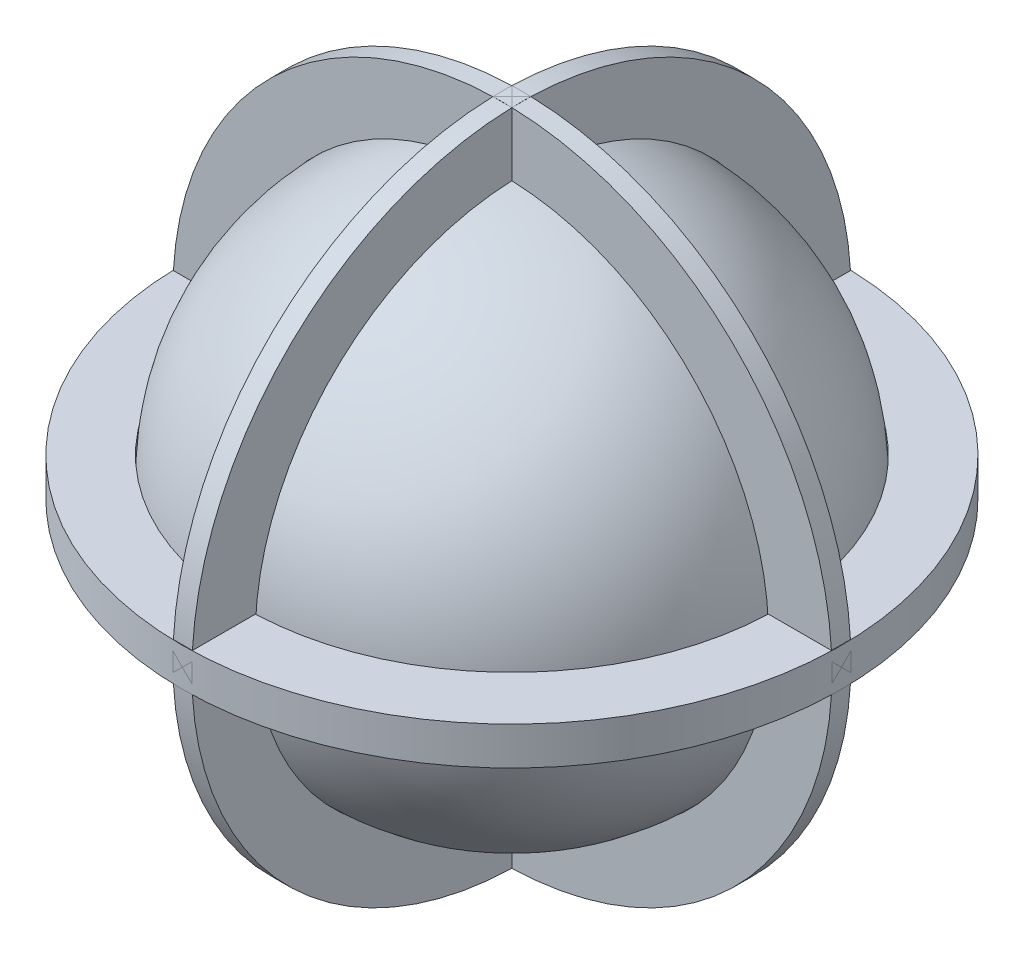
from build123d import *

# Parameters (mm, degrees)
SKETCH2_R           = 52
SKETCH2_R_2         = 42
BOSS_EXTRUDE1_DEPTH = 1.5
SKETCH4_R           = 52
SKETCH4_R_2         = 42
BOSS_EXTRUDE2_DEPTH = 1.5
SKETCH5_R           = 52
SKETCH5_R_2         = 42
BOSS_EXTRUDE3_DEPTH = 3


with BuildPart() as part:
    # Sketch1 one side → Revolve3 (revolve)
    with BuildSketch(Plane.XY):
        with BuildLine():
            Line((0, 40), (0, 42))
            ThreePointArc((0, 42), (-42, 0), (0, -42))
            Line((0, -42), (0, -40))
            ThreePointArc((0, -40), (-40, 0), (0, 40))
        make_face()
    revolve(axis=Axis((0, 0, 0), (0, 1, 0)))


with BuildPart() as body_2:
    # Sketch2 → Boss-Extrude1 (new body, symmetric)
    with BuildSketch(Plane.XY):
        Circle(SKETCH2_R)
        Circle(SKETCH2_R_2, mode=Mode.SUBTRACT)
    extrude(amount=BOSS_EXTRUDE1_DEPTH, both=True)

    # Sketch4 → Boss-Extrude2 (add, symmetric)
    with BuildSketch(Plane(origin=(0, 0, 0), x_dir=(0, 0, -1), z_dir=(1, 0, 0))):
        Circle(SKETCH4_R)
        Circle(SKETCH4_R_2, mode=Mode.SUBTRACT)
    extrude(amount=BOSS_EXTRUDE2_DEPTH, both=True)

    # Sketch5 → Boss-Extrude3 (add, symmetric)
    with BuildSketch(Plane(origin=(0, 0, 0), x_dir=(1, 0, 0), z_dir=(0, 1, 0))):
        Circle(SKETCH5_R)
        Circle(SKETCH5_R_2, mode=Mode.SUBTRACT)
    extrude(amount=BOSS_EXTRUDE3_DEPTH, both=True)


solid = Compound([part.part, body_2.part])
